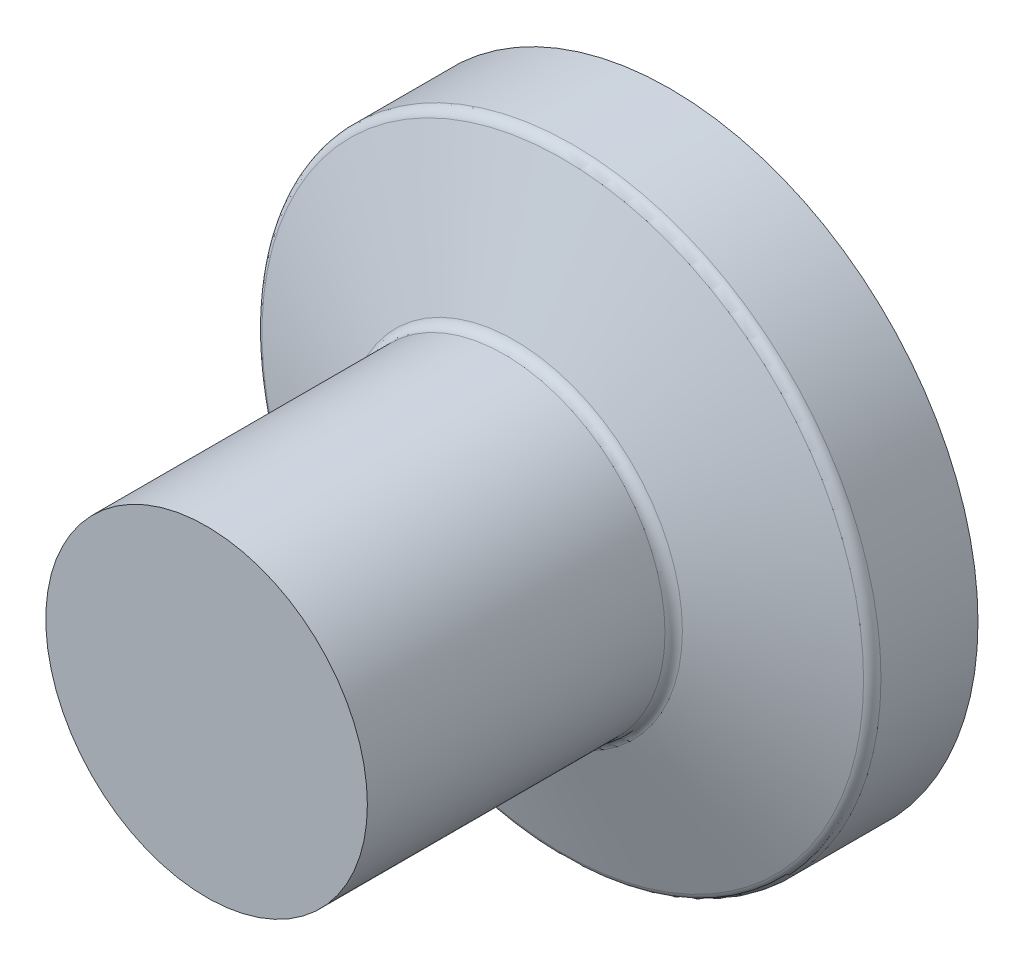
from build123d import *


with BuildPart() as part:
    # Sketch1 → Revolve1 (revolve)
    with BuildSketch(Plane(origin=(0, 0, 0), x_dir=(0, 0, -1), z_dir=(1, 0, 0))):
        with BuildLine():
            Line((0, 0), (0, 14.75))
            Line((0, 14.75), (27.299792462, 14.75))
            ThreePointArc((27.299792462, 14.75), (27.873368898, 14.930847956), (28.239485083, 15.407979857))
            Line((28.239485083, 15.407979857), (32.67411308, 27.592020143))
            ThreePointArc((32.67411308, 27.592020143), (33.040229264, 28.069152044), (33.613805701, 28.25))
            Line((33.613805701, 28.25), (42.513598163, 28.25))
            Line((42.513598163, 28.25), (42.513598163, 24.25))
            ThreePointArc((42.513598163, 24.25), (49.544009667, 13.019738091), (52, 0))
            Line((52, 0), (0, 0))
        make_face()
    revolve(axis=Axis((0, 0, 0), (0, 0, -1)))


solid = part.part
